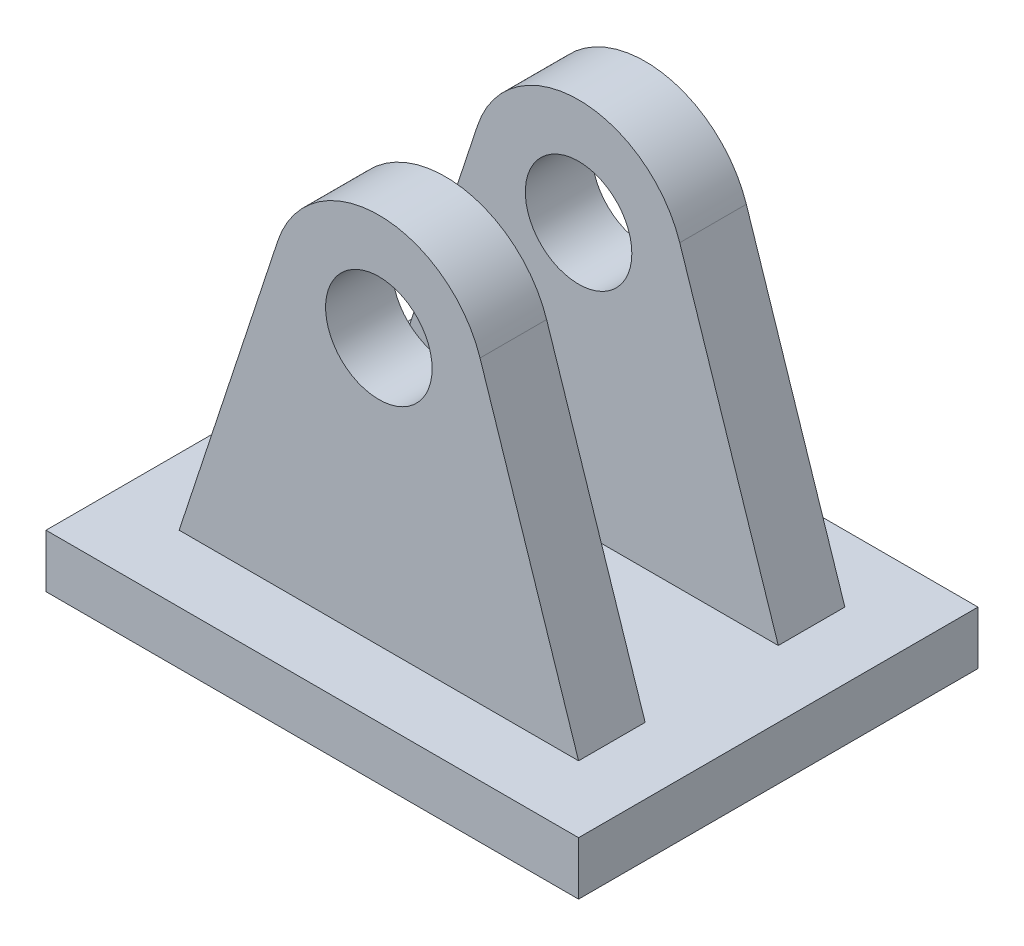
from build123d import *

# Parameters (mm, degrees)
SKETCH1_W           = 200
SKETCH1_H           = 150
BOSS_EXTRUDE1_DEPTH = 20
BOSS_EXTRUDE2_DEPTH = 50
CUT_EXTRUDE1_DEPTH  = 25
SKETCH6_R           = 20
CUT_EXTRUDE2_DEPTH  = 227.329405955


with BuildPart() as part:
    # Sketch1 → Boss-Extrude1 (new body)
    with BuildSketch(Plane(origin=(0, 0, 0), x_dir=(1, 0, 0), z_dir=(0, 1, 0))):
        Rectangle(SKETCH1_W, SKETCH1_H)
    extrude(amount=BOSS_EXTRUDE1_DEPTH)

    # Sketch3 → Boss-Extrude2 (add, symmetric)
    with BuildSketch(Plane.XY):
        with BuildLine():
            Line((-37.997361363, 132.498021022), (-75, 20))
            Line((-75, 20), (75, 20))
            Line((75, 20), (37.997361363, 132.498021022))
            ThreePointArc((37.997361363, 132.498021022), (0, 160), (-37.997361363, 132.498021022))
        make_face()
    extrude(amount=BOSS_EXTRUDE2_DEPTH, both=True)

    # Sketch5 → Cut-Extrude1 (cut, symmetric)
    with BuildSketch(Plane.XY):
        with BuildLine():
            Line((-37.997361363, 132.498021022), (-75, 20))
            Line((-75, 20), (75, 20))
            Line((75, 20), (37.997361363, 132.498021022))
            ThreePointArc((37.997361363, 132.498021022), (0, 160), (-37.997361363, 132.498021022))
        make_face()
    extrude(amount=CUT_EXTRUDE1_DEPTH, both=True, mode=Mode.SUBTRACT)

    # Sketch6 → Cut-Extrude2 (cut, through all)
    with BuildSketch(Plane.XY.offset(50)):
        with Locations((0, 120)):
            Circle(SKETCH6_R)
    extrude(amount=-CUT_EXTRUDE2_DEPTH, mode=Mode.SUBTRACT)


solid = part.part
